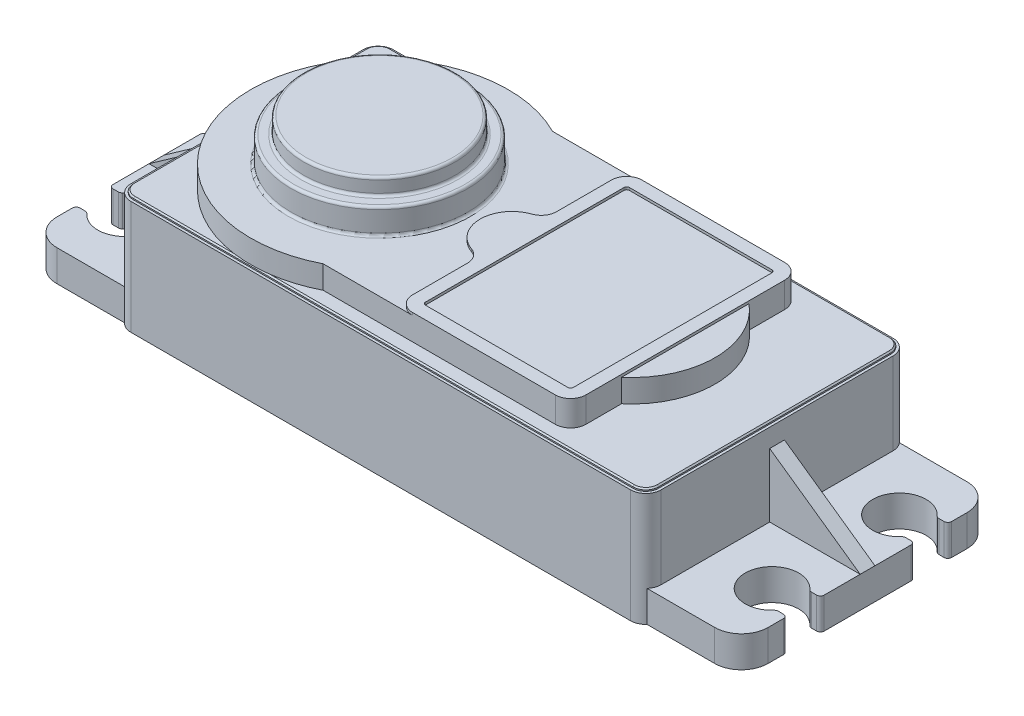
from build123d import *

# Parameters (mm, degrees)
CROQUIS1_W              = 41.6
CROQUIS1_H              = 20.6
SALIENTE_EXTRUIR1_DEPTH = 8.9
REDONDEO1_R             = 1.2
CROQUIS2_W              = 55.8
CROQUIS2_H              = 19.8
SALIENTE_EXTRUIR2_DEPTH = 2.45
REDONDEO2_R             = 2.1
CORTAR_EXTRUIR1_DEPTH   = 2.45
REDONDEO3_R             = 0.3
SALIENTE_EXTRUIR3_DEPTH = 0.2
CHAFL_N1_SIZE           = 0.1
SALIENTE_EXTRUIR4_DEPTH = 1.8
REDONDEO5_R             = 1.2
SALIENTE_EXTRUIR5_DEPTH = 0.2
CROQUIS11_R             = 6.95
SALIENTE_EXTRUIR6_DEPTH = 2
REDONDEO6_R             = 0.2
CROQUIS12_R             = 5.95
SALIENTE_EXTRUIR7_DEPTH = 1.3
REDONDEO7_R             = 0.2
SALIENTE_EXTRUIR8_DEPTH = 0.58


with BuildPart() as part:
    # Croquis1 → Saliente-Extruir1 (new body)
    with BuildSketch(Plane(origin=(0, 0, 0), x_dir=(1, 0, 0), z_dir=(0, 1, 0))):
        Rectangle(CROQUIS1_W, CROQUIS1_H)
    extrude(amount=SALIENTE_EXTRUIR1_DEPTH)

    # Redondeo1
    redondeo1_edges = [part.edges().sort_by_distance(p)[0] for p in [
        (20.8, 4.45, 10.3),
        (-20.8, 4.45, 10.3),
        (-20.8, 4.45, -10.3),
        (20.8, 4.45, -10.3),
    ]]
    fillet(redondeo1_edges, radius=REDONDEO1_R)

    # Croquis2 → Saliente-Extruir2 (add)
    with BuildSketch(Plane.XZ):
        Rectangle(CROQUIS2_W, CROQUIS2_H)
    extrude(amount=-SALIENTE_EXTRUIR2_DEPTH)

    # Redondeo2
    redondeo2_edges = [part.edges().sort_by_distance(p)[0] for p in [
        (-27.9, 1.225, -9.9),
        (-27.9, 1.225, 9.9),
        (27.9, 1.225, 9.9),
        (27.9, 1.225, -9.9),
    ]]
    fillet(redondeo2_edges, radius=REDONDEO2_R)

    # Croquis3 → Cortar-Extruir1 (cut)
    with BuildSketch(Plane.XZ):
        with BuildLine():
            Line((27.04924225, 6.3), (27.9, 6.3))
            Line((27.9, 6.3), (27.9, 3.7))
            Line((27.9, 3.7), (27.04924225, 3.7))
            ThreePointArc((27.04924225, 3.7), (23.3, 5), (27.04924225, 6.3))
        make_face()
        with BuildLine():
            Line((27.9, -6.3), (27.9, -3.7))
            Line((27.9, -3.7), (27.04924225, -3.7))
            ThreePointArc((27.04924225, -3.7), (23.3, -5), (27.04924225, -6.3))
            Line((27.04924225, -6.3), (27.9, -6.3))
        make_face()
        with BuildLine():
            Line((-27.04924225, -6.3), (-27.9, -6.3))
            Line((-27.9, -6.3), (-27.9, -3.7))
            Line((-27.9, -3.7), (-27.04924225, -3.7))
            ThreePointArc((-27.04924225, -3.7), (-23.3, -5), (-27.04924225, -6.3))
        make_face()
        with BuildLine():
            Line((-27.9, 6.3), (-27.9, 3.7))
            Line((-27.9, 3.7), (-27.04924225, 3.7))
            ThreePointArc((-27.04924225, 3.7), (-23.3, 5), (-27.04924225, 6.3))
            Line((-27.04924225, 6.3), (-27.9, 6.3))
        make_face()
    extrude(amount=-CORTAR_EXTRUIR1_DEPTH, mode=Mode.SUBTRACT)

    # Redondeo3
    redondeo3_edges = [part.edges().sort_by_distance(p)[0] for p in [
        (27.04924225, 1.225, 3.7),
        (27.04924225, 1.225, 6.3),
        (27.9, 1.225, 6.3),
        (27.9, 1.225, 3.7),
        (27.9, 1.225, -6.3),
        (27.04924225, 1.225, -6.3),
        (27.04924225, 1.225, -3.7),
        (27.9, 1.225, -3.7),
        (-27.9, 1.225, 6.3),
        (-27.04924225, 1.225, 6.3),
        (-27.04924225, 1.225, 3.7),
        (-27.9, 1.225, 3.7),
        (-27.9, 1.225, -6.3),
        (-27.9, 1.225, -3.7),
        (-27.04924225, 1.225, -3.7),
        (-27.04924225, 1.225, -6.3),
    ]]
    fillet(redondeo3_edges, radius=REDONDEO3_R)

    # Croquis4 → Saliente-Extruir3 (add)
    with BuildSketch(Plane(origin=(0, 8.9, 0), x_dir=(1, 0, 0), z_dir=(0, 1, 0))):
        with BuildLine():
            Line((20.6, -9.1), (20.6, 9.1))
            ThreePointArc((20.6, 9.1), (20.307106781, 9.807106781), (19.6, 10.1))
            Line((19.6, 10.1), (-19.6, 10.1))
            ThreePointArc((-19.6, 10.1), (-20.307106781, 9.807106781), (-20.6, 9.1))
            Line((-20.6, 9.1), (-20.6, -9.1))
            ThreePointArc((-20.6, -9.1), (-20.307106781, -9.807106781), (-19.6, -10.1))
            Line((-19.6, -10.1), (19.6, -10.1))
            ThreePointArc((19.6, -10.1), (20.307106781, -9.807106781), (20.6, -9.1))
        make_face()
    extrude(amount=SALIENTE_EXTRUIR3_DEPTH)

    # Chaflán1
    chafl_n1_edges = [part.edges().sort_by_distance(p)[0] for p in [
        (20.307106781, 9.1, -9.807106781),
        (0, 9.1, -10.1),
        (-20.307106781, 9.1, -9.807106781),
        (-20.6, 9.1, 0),
        (-20.307106781, 9.1, 9.807106781),
        (0, 9.1, 10.1),
        (20.307106781, 9.1, 9.807106781),
        (20.6, 9.1, 0),
    ]]
    chamfer(chafl_n1_edges, length=CHAFL_N1_SIZE)

    # Croquis6 → Saliente-Extruir4 (add)
    with BuildSketch(Plane(origin=(0, 9.1, 0), x_dir=(1, 0, 0), z_dir=(0, 1, 0))):
        with BuildLine():
            Line((13.6, 5), (13.6, 9))
            Line((13.6, 9), (-5.816333345, 9))
            ThreePointArc((-5.816333345, 9), (-20.5, 0), (-5.816333345, -9))
            Line((-5.816333345, -9), (13.6, -9))
            Line((13.6, -9), (13.6, -5))
            ThreePointArc((13.6, -5), (15.94, 0), (13.6, 5))
        make_face()
    extrude(amount=SALIENTE_EXTRUIR4_DEPTH)

    # Redondeo5
    redondeo5_edges = [part.edges().sort_by_distance(p)[0] for p in [
        (13.6, 10, -9),
        (13.6, 10, 9),
    ]]
    fillet(redondeo5_edges, radius=REDONDEO5_R)

    # Croquis10 → Saliente-Extruir5 (add)
    with BuildSketch(Plane(origin=(0, 10.9, 0), x_dir=(1, 0, 0), z_dir=(0, 1, 0))):
        with BuildLine():
            Line((13.6, 7.8), (13.6, -7.8))
            ThreePointArc((13.6, -7.8), (13.248528137, -8.648528137), (12.4, -9))
            Line((12.4, -9), (1.2, -9))
            ThreePointArc((1.2, -9), (0.351471863, -8.648528137), (0, -7.8))
            Line((0, -7.8), (0, -3.5))
            ThreePointArc((0, -3.5), (-0.223519835, -2.802514168), (-0.810810811, -2.364864865))
            ThreePointArc((-0.810810811, -2.364864865), (-2.5, 0), (-0.810810811, 2.364864865))
            ThreePointArc((-0.810810811, 2.364864865), (-0.223519835, 2.802514168), (0, 3.5))
            Line((0, 3.5), (0, 7.8))
            ThreePointArc((0, 7.8), (0.351471863, 8.648528137), (1.2, 9))
            Line((1.2, 9), (12.4, 9))
            ThreePointArc((12.4, 9), (13.248528137, 8.648528137), (13.6, 7.8))
        make_face()
        with BuildLine():
            Line((12.4, 8), (1.2, 8))
            ThreePointArc((1.2, 8), (1.058578644, 7.941421356), (1, 7.8))
            Line((1, 7.8), (1, -7.8))
            ThreePointArc((1, -7.8), (1.058578644, -7.941421356), (1.2, -8))
            Line((1.2, -8), (12.4, -8))
            ThreePointArc((12.4, -8), (12.541421356, -7.941421356), (12.6, -7.8))
            Line((12.6, -7.8), (12.6, 7.8))
            ThreePointArc((12.6, 7.8), (12.541421356, 7.941421356), (12.4, 8))
        make_face(mode=Mode.SUBTRACT)
    extrude(amount=SALIENTE_EXTRUIR5_DEPTH)

    # Croquis11 → Saliente-Extruir6 (add)
    with BuildSketch(Plane(origin=(0, 10.9, 0), x_dir=(1, 0, 0), z_dir=(0, 1, 0))):
        with Locations((-10.4, 0)):
            Circle(CROQUIS11_R)
    extrude(amount=SALIENTE_EXTRUIR6_DEPTH)

    # Redondeo6
    redondeo6_edges = [part.edges().sort_by_distance(p)[0] for p in [
        (-17.35, 10.9, 0),
        (-17.35, 12.9, 0),
    ]]
    fillet(redondeo6_edges, radius=REDONDEO6_R)

    # Croquis12 → Saliente-Extruir7 (add)
    with BuildSketch(Plane(origin=(0, 12.9, 0), x_dir=(1, 0, 0), z_dir=(0, 1, 0))):
        with Locations((-10.4, 0)):
            Circle(CROQUIS12_R)
    extrude(amount=SALIENTE_EXTRUIR7_DEPTH)

    # Redondeo7
    redondeo7_edges = [part.edges().sort_by_distance(p)[0] for p in [
        (-16.35, 12.9, 0),
        (-16.35, 14.2, 0),
    ]]
    fillet(redondeo7_edges, radius=REDONDEO7_R)

    # Croquis13 → Saliente-Extruir8 (add, symmetric)
    with BuildSketch(Plane.XY):
        Polygon((20.8, 2.45), (27.9, 2.45), (20.8, 7.45), align=None)
        Polygon((-27.9, 2.45), (-20.8, 2.45), (-20.8, 7.45), align=None)
    extrude(amount=SALIENTE_EXTRUIR8_DEPTH, both=True)


solid = part.part
